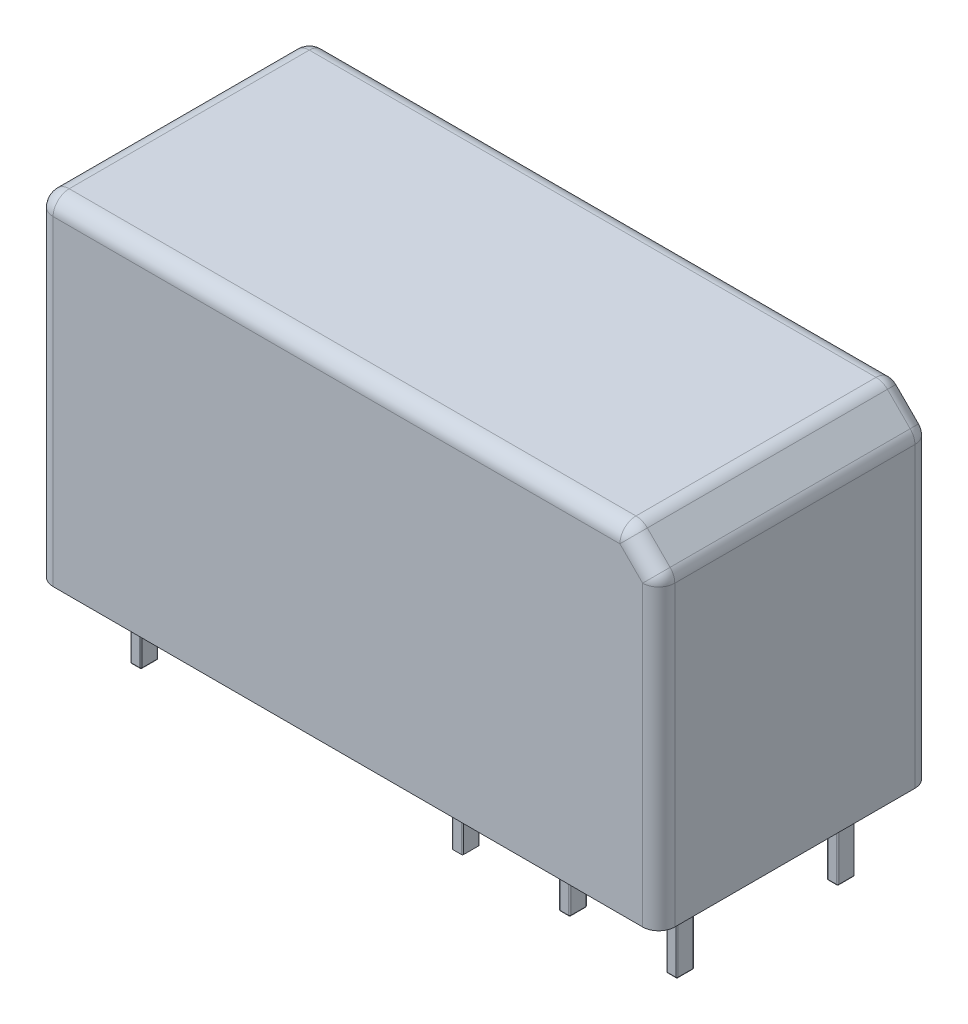
from build123d import *

# Parameters (mm, degrees)
SKETCH_1_W      = 29
SKETCH_1_H      = 12.7
EXTRUDE_1_DEPTH = 15.7
EXTRUDE_2_DEPTH = 3.5
FILLET_1_R      = 0.05
CHAMFER_1_SIZE  = 1.5
FILLET_2_R      = 0.75


with BuildPart() as part:
    # Эскиз1 → Бобышка-Вытянуть1 (new body)
    with BuildSketch(Plane(origin=(0, 0, 0), x_dir=(1, 0, 0), z_dir=(0, 1, 0))):
        Rectangle(SKETCH_1_W, SKETCH_1_H)
    extrude(amount=EXTRUDE_1_DEPTH)

    # Эскиз2 → Бобышка-Вытянуть2 (add)
    with BuildSketch(Plane.XZ):
        with BuildLine():
            Line((-12.3, 4.15), (-11.9, 4.15))
            ThreePointArc((-11.9, 4.15), (-11.864644661, 4.135355339), (-11.85, 4.1))
            Line((-11.85, 4.1), (-11.85, 3.4))
            ThreePointArc((-11.85, 3.4), (-11.864644661, 3.364644661), (-11.9, 3.35))
            Line((-11.9, 3.35), (-12.3, 3.35))
            ThreePointArc((-12.3, 3.35), (-12.335355339, 3.364644661), (-12.35, 3.4))
            Line((-12.35, 3.4), (-12.35, 4.1))
            ThreePointArc((-12.35, 4.1), (-12.335355339, 4.135355339), (-12.3, 4.15))
        make_face()
        with BuildLine():
            Line((2.65, 4.1), (2.65, 3.4))
            ThreePointArc((2.65, 3.4), (2.664644661, 3.364644661), (2.7, 3.35))
            Line((2.7, 3.35), (3.1, 3.35))
            ThreePointArc((3.1, 3.35), (3.135355339, 3.364644661), (3.15, 3.4))
            Line((3.15, 3.4), (3.15, 4.1))
            ThreePointArc((3.15, 4.1), (3.135355339, 4.135355339), (3.1, 4.15))
            Line((3.1, 4.15), (2.7, 4.15))
            ThreePointArc((2.7, 4.15), (2.664644661, 4.135355339), (2.65, 4.1))
        make_face()
        with BuildLine():
            Line((7.65, 4.1), (7.65, 3.4))
            ThreePointArc((7.65, 3.4), (7.664644661, 3.364644661), (7.7, 3.35))
            Line((7.7, 3.35), (8.1, 3.35))
            ThreePointArc((8.1, 3.35), (8.135355339, 3.364644661), (8.15, 3.4))
            Line((8.15, 3.4), (8.15, 4.1))
            ThreePointArc((8.15, 4.1), (8.135355339, 4.135355339), (8.1, 4.15))
            Line((8.1, 4.15), (7.7, 4.15))
            ThreePointArc((7.7, 4.15), (7.664644661, 4.135355339), (7.65, 4.1))
        make_face()
        with BuildLine():
            Line((12.65, 4.1), (12.65, 3.4))
            ThreePointArc((12.65, 3.4), (12.664644661, 3.364644661), (12.7, 3.35))
            Line((12.7, 3.35), (13.1, 3.35))
            ThreePointArc((13.1, 3.35), (13.135355339, 3.364644661), (13.15, 3.4))
            Line((13.15, 3.4), (13.15, 4.1))
            ThreePointArc((13.15, 4.1), (13.135355339, 4.135355339), (13.1, 4.15))
            Line((13.1, 4.15), (12.7, 4.15))
            ThreePointArc((12.7, 4.15), (12.664644661, 4.135355339), (12.65, 4.1))
        make_face()
        with BuildLine():
            Line((2.65, -3.4), (2.65, -4.1))
            ThreePointArc((2.65, -4.1), (2.664644661, -4.135355339), (2.7, -4.15))
            Line((2.7, -4.15), (3.1, -4.15))
            ThreePointArc((3.1, -4.15), (3.135355339, -4.135355339), (3.15, -4.1))
            Line((3.15, -4.1), (3.15, -3.4))
            ThreePointArc((3.15, -3.4), (3.135355339, -3.364644661), (3.1, -3.35))
            Line((3.1, -3.35), (2.7, -3.35))
            ThreePointArc((2.7, -3.35), (2.664644661, -3.364644661), (2.65, -3.4))
        make_face()
        with BuildLine():
            Line((7.65, -3.4), (7.65, -4.1))
            ThreePointArc((7.65, -4.1), (7.664644661, -4.135355339), (7.7, -4.15))
            Line((7.7, -4.15), (8.1, -4.15))
            ThreePointArc((8.1, -4.15), (8.135355339, -4.135355339), (8.15, -4.1))
            Line((8.15, -4.1), (8.15, -3.4))
            ThreePointArc((8.15, -3.4), (8.135355339, -3.364644661), (8.1, -3.35))
            Line((8.1, -3.35), (7.7, -3.35))
            ThreePointArc((7.7, -3.35), (7.664644661, -3.364644661), (7.65, -3.4))
        make_face()
        with BuildLine():
            Line((12.65, -3.4), (12.65, -4.1))
            ThreePointArc((12.65, -4.1), (12.664644661, -4.135355339), (12.7, -4.15))
            Line((12.7, -4.15), (13.1, -4.15))
            ThreePointArc((13.1, -4.15), (13.135355339, -4.135355339), (13.15, -4.1))
            Line((13.15, -4.1), (13.15, -3.4))
            ThreePointArc((13.15, -3.4), (13.135355339, -3.364644661), (13.1, -3.35))
            Line((13.1, -3.35), (12.7, -3.35))
            ThreePointArc((12.7, -3.35), (12.664644661, -3.364644661), (12.65, -3.4))
        make_face()
        with BuildLine():
            Line((-12.35, -3.4), (-12.35, -4.1))
            ThreePointArc((-12.35, -4.1), (-12.335355339, -4.135355339), (-12.3, -4.15))
            Line((-12.3, -4.15), (-11.9, -4.15))
            ThreePointArc((-11.9, -4.15), (-11.864644661, -4.135355339), (-11.85, -4.1))
            Line((-11.85, -4.1), (-11.85, -3.4))
            ThreePointArc((-11.85, -3.4), (-11.864644661, -3.364644661), (-11.9, -3.35))
            Line((-11.9, -3.35), (-12.3, -3.35))
            ThreePointArc((-12.3, -3.35), (-12.335355339, -3.364644661), (-12.35, -3.4))
        make_face()
    extrude(amount=EXTRUDE_2_DEPTH)

    # Скругление1
    fillet_1_edges = [part.edges().sort_by_distance(p)[0] for p in [
        (7.664644661, -3.5, -4.135355339),
        (7.9, -3.5, -4.15),
        (8.135355339, -3.5, -4.135355339),
        (8.15, -3.5, -3.75),
        (8.135355339, -3.5, -3.364644661),
        (7.9, -3.5, -3.35),
        (7.664644661, -3.5, -3.364644661),
        (7.65, -3.5, -3.75),
        (12.664644661, -3.5, -4.135355339),
        (12.9, -3.5, -4.15),
        (13.135355339, -3.5, -4.135355339),
        (13.15, -3.5, -3.75),
        (13.135355339, -3.5, -3.364644661),
        (12.9, -3.5, -3.35),
        (12.664644661, -3.5, -3.364644661),
        (12.65, -3.5, -3.75),
        (-12.335355339, -3.5, -4.135355339),
        (-12.1, -3.5, -4.15),
        (-11.864644661, -3.5, -4.135355339),
        (-11.85, -3.5, -3.75),
        (-11.864644661, -3.5, -3.364644661),
        (-12.1, -3.5, -3.35),
        (-12.335355339, -3.5, -3.364644661),
        (-12.35, -3.5, -3.75),
        (-12.335355339, -3.5, 3.364644661),
        (-12.1, -3.5, 3.35),
        (-11.864644661, -3.5, 3.364644661),
        (-11.85, -3.5, 3.75),
        (-11.864644661, -3.5, 4.135355339),
        (-12.1, -3.5, 4.15),
        (-12.335355339, -3.5, 4.135355339),
        (-12.35, -3.5, 3.75),
        (7.664644661, -3.5, 3.364644661),
        (7.9, -3.5, 3.35),
        (8.135355339, -3.5, 3.364644661),
        (8.15, -3.5, 3.75),
        (8.135355339, -3.5, 4.135355339),
        (7.9, -3.5, 4.15),
        (7.664644661, -3.5, 4.135355339),
        (7.65, -3.5, 3.75),
        (12.664644661, -3.5, 3.364644661),
        (12.9, -3.5, 3.35),
        (13.135355339, -3.5, 3.364644661),
        (13.15, -3.5, 3.75),
        (13.135355339, -3.5, 4.135355339),
        (12.9, -3.5, 4.15),
        (12.664644661, -3.5, 4.135355339),
        (12.65, -3.5, 3.75),
    ]]
    fillet(fillet_1_edges, radius=FILLET_1_R)

    # Фаска1
    chamfer_1_edges = [part.edges().sort_by_distance(p)[0] for p in [
        (14.5, 15.7, 0),
    ]]
    chamfer(chamfer_1_edges, length=CHAMFER_1_SIZE)

    # Скругление2
    fillet_2_edges = [part.edges().sort_by_distance(p)[0] for p in [
        (-14.5, 15.7, 0),
        (-0.75, 15.7, 6.35),
        (-0.75, 15.7, -6.35),
        (13, 15.7, 0),
        (14.5, 7.1, -6.35),
        (13.75, 14.95, -6.35),
        (14.5, 7.1, 6.35),
        (14.5, 14.2, 0),
        (13.75, 14.95, 6.35),
        (-14.5, 7.85, 6.35),
        (-14.5, 7.85, -6.35),
    ]]
    fillet(fillet_2_edges, radius=FILLET_2_R)


solid = part.part
